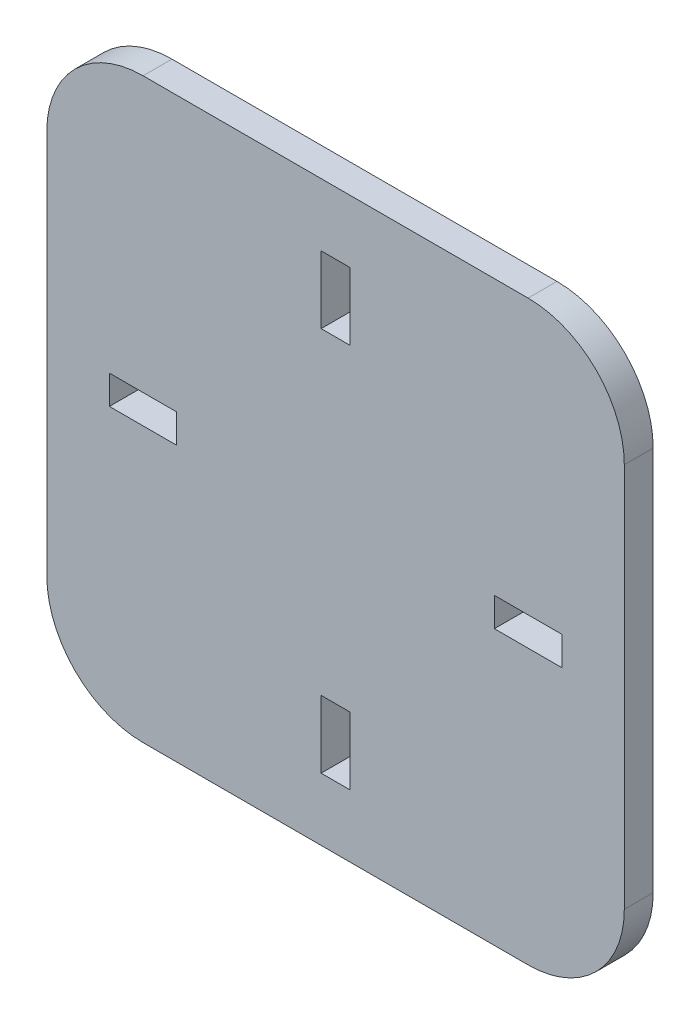
from build123d import *

# Parameters (mm, degrees)
ESBO_O1_W                = 60
ESBO_O1_H                = 60
RESSALTO_EXTRUS_O1_DEPTH = 3
ESBO_O2_W                = 7
ESBO_O2_H                = 3
ESBO_O2_W_2              = 3
ESBO_O2_H_2              = 7
CORTE_EXTRUS_O1_DEPTH    = 3
FILETE1_R                = 10


with BuildPart() as part:
    # Esboço1 → Ressalto-extrusão1 (new body)
    with BuildSketch(Plane.XY):
        Rectangle(ESBO_O1_W, ESBO_O1_H)
    extrude(amount=RESSALTO_EXTRUS_O1_DEPTH)

    # Esboço2 → Corte-extrusão1 (cut)
    with BuildSketch(Plane.XY.offset(3)):
        with Locations((20, 0)):
            Rectangle(ESBO_O2_W, ESBO_O2_H)
        with Locations((0, -20)):
            Rectangle(ESBO_O2_W_2, ESBO_O2_H_2)
        with Locations((-20, 0)):
            Rectangle(ESBO_O2_W, ESBO_O2_H)
        with Locations((0, 20)):
            Rectangle(ESBO_O2_W_2, ESBO_O2_H_2)
    extrude(amount=-CORTE_EXTRUS_O1_DEPTH, mode=Mode.SUBTRACT)

    # Filete1
    filete1_edges = [part.edges().sort_by_distance(p)[0] for p in [
        (30, -30, 1.5),
        (-30, -30, 1.5),
        (-30, 30, 1.5),
        (30, 30, 1.5),
    ]]
    fillet(filete1_edges, radius=FILETE1_R)


solid = part.part
